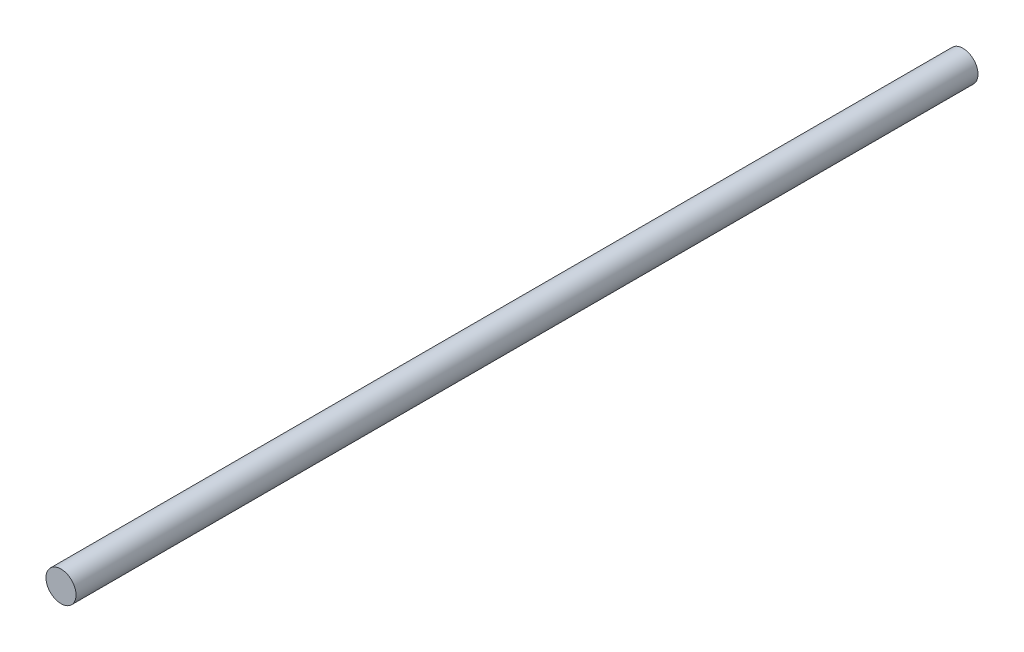
from build123d import *

# Parameters (mm, degrees)
SKETCH1_R           = 6.35
BOSS_EXTRUDE1_DEPTH = 381


with BuildPart() as part:
    # Sketch1 → Boss-Extrude1 (new body)
    with BuildSketch(Plane.XY):
        Circle(SKETCH1_R)
    extrude(amount=BOSS_EXTRUDE1_DEPTH)


solid = part.part
